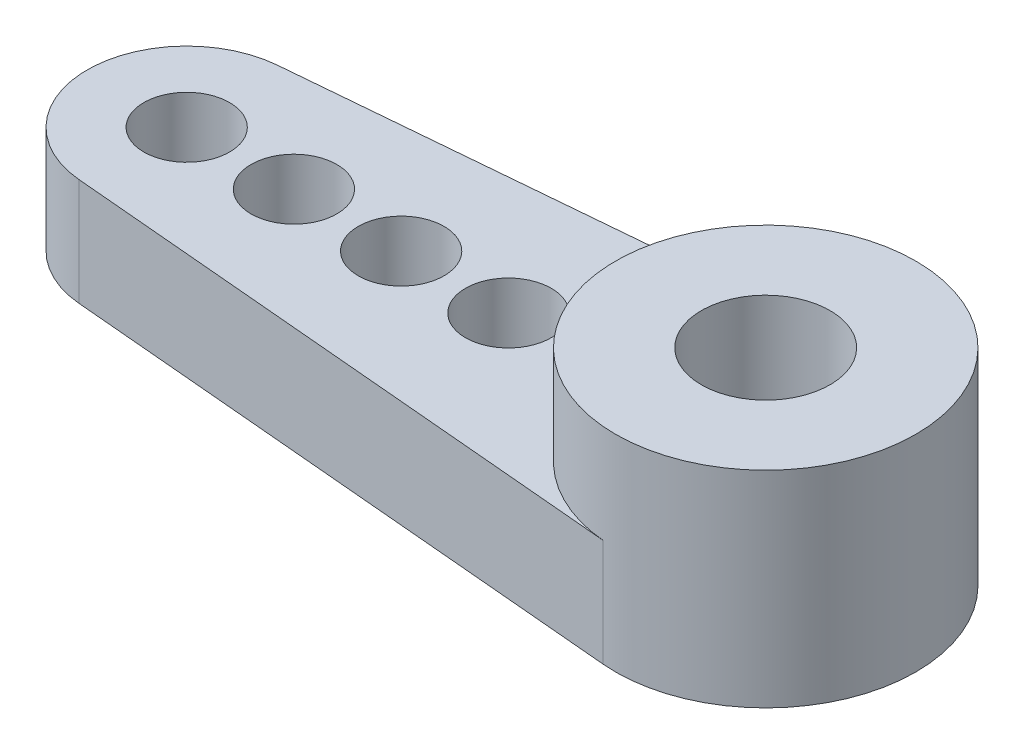
from build123d import *

# Parameters (mm, degrees)
SKETCH_1_R      = 1
EXTRUDE_1_DEPTH = 2.5
SKETCH_1_3_R    = 1.5
EXTRUDE_2_DEPTH = 4.8


with BuildPart() as part:
    # 草图1 → 凸台-拉伸1 (new body)
    with BuildSketch(Plane(origin=(0, 0, 0), x_dir=(1, 0, 0), z_dir=(0, 1, 0))):
        with BuildLine():
            ThreePointArc((-0.305925926, -3.486604269), (-3.5, 0), (-0.305925926, 3.486604269))
            Line((-0.305925926, 3.486604269), (-13.702785185, 2.311120544))
            ThreePointArc((-13.702785185, 2.311120544), (-15.82, 0), (-13.702785185, -2.311120544))
            Line((-13.702785185, -2.311120544), (-0.305925926, -3.486604269))
        make_face()
        with Locations((-13.5, 0)):
            Circle(SKETCH_1_R, mode=Mode.SUBTRACT)
        with Locations((-11, 0)):
            Circle(SKETCH_1_R, mode=Mode.SUBTRACT)
        with Locations((-8.5, 0)):
            Circle(SKETCH_1_R, mode=Mode.SUBTRACT)
        with Locations((-6, 0)):
            Circle(SKETCH_1_R, mode=Mode.SUBTRACT)
    extrude(amount=EXTRUDE_1_DEPTH)

    # 草图1<3> → 凸台-拉伸2 (add)
    with BuildSketch(Plane(origin=(0, 0, 0), x_dir=(1, 0, 0), z_dir=(0, 1, 0))):
        with BuildLine():
            ThreePointArc((3.5, 0), (2.364239757, 2.580769337), (-0.305925926, 3.486604269))
            ThreePointArc((-0.305925926, 3.486604269), (-3.5, 0), (-0.305925926, -3.486604269))
            ThreePointArc((-0.305925926, -3.486604269), (2.364239757, -2.580769337), (3.5, 0))
        make_face()
        Circle(SKETCH_1_3_R, mode=Mode.SUBTRACT)
    extrude(amount=EXTRUDE_2_DEPTH)


solid = part.part
